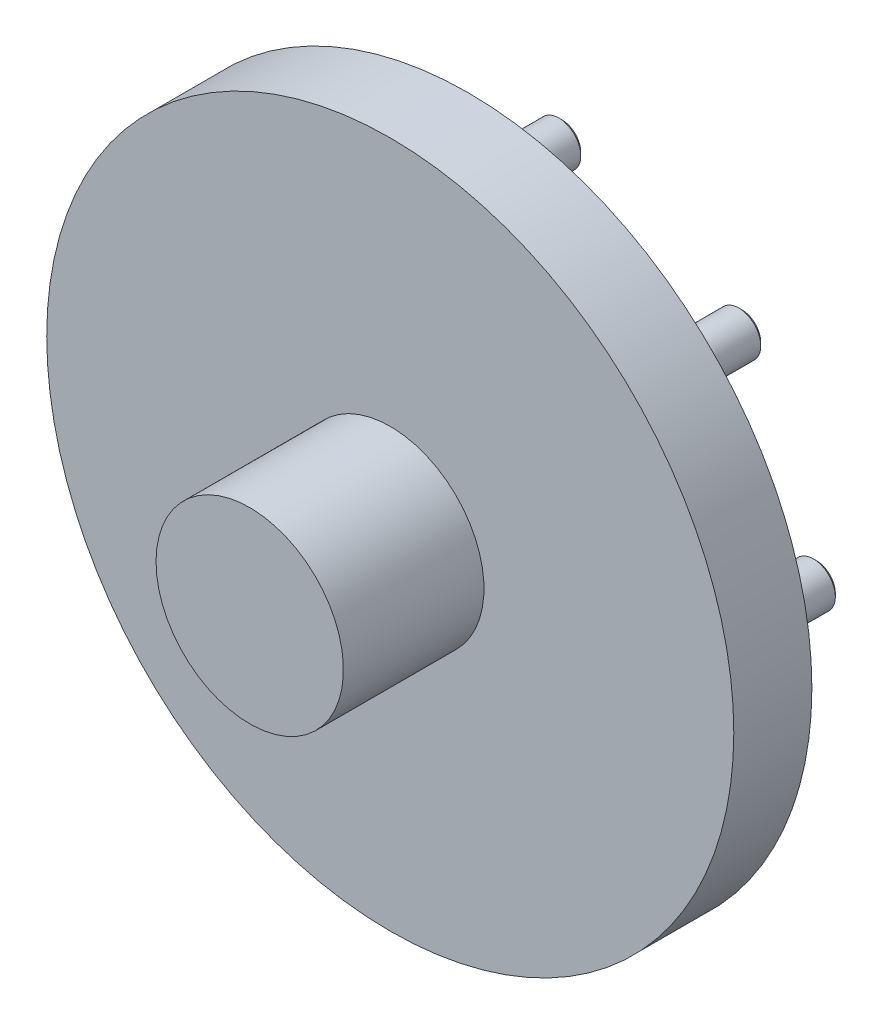
from build123d import *

# Parameters (mm, degrees)
SKETCH7_R           = 7
BOSS_EXTRUDE2_DEPTH = 30
CHAMFER2_SIZE       = 1


with BuildPart() as part:
    # Sketch6 → Revolve2 (revolve)
    with BuildSketch(Plane.XZ):
        Polygon((30, 75), (0, 75), (0, 0), (53, 0), (53, 5), (110, 5), (110, 30), (30, 30), align=None)
    revolve(axis=Axis((0, 0, 75), (0, 0, -1)))

    # Sketch7 → Boss-Extrude2 (add)
    with BuildSketch(Plane(origin=(0, 0, 5), x_dir=(-1, 0, 0), z_dir=(0, 0, -1))):
        with Locations((-57.629202667, -57.629202667)):
            Circle(SKETCH7_R)
        with Locations((-81.5, 0)):
            Circle(SKETCH7_R)
        with Locations((-57.629202667, 57.629202667)):
            Circle(SKETCH7_R)
        with Locations((0, 81.5)):
            Circle(SKETCH7_R)
        with Locations((57.629202667, 57.629202667)):
            Circle(SKETCH7_R)
        with Locations((81.5, 0)):
            Circle(SKETCH7_R)
        with Locations((0, -81.5)):
            Circle(SKETCH7_R)
        with Locations((57.629202667, -57.629202667)):
            Circle(SKETCH7_R)
    extrude(amount=BOSS_EXTRUDE2_DEPTH)

    # Chamfer2
    chamfer2_edges = [part.edges().sort_by_distance(p)[0] for p in [
        (64.629202667, -57.629202667, -25),
        (88.5, 0, -25),
        (64.629202667, 57.629202667, -25),
        (7, 81.5, -25),
        (-50.629202667, 57.629202667, -25),
        (7, -81.5, -25),
        (-74.5, 0, -25),
        (-50.629202667, -57.629202667, -25),
    ]]
    chamfer(chamfer2_edges, length=CHAMFER2_SIZE)


solid = part.part
